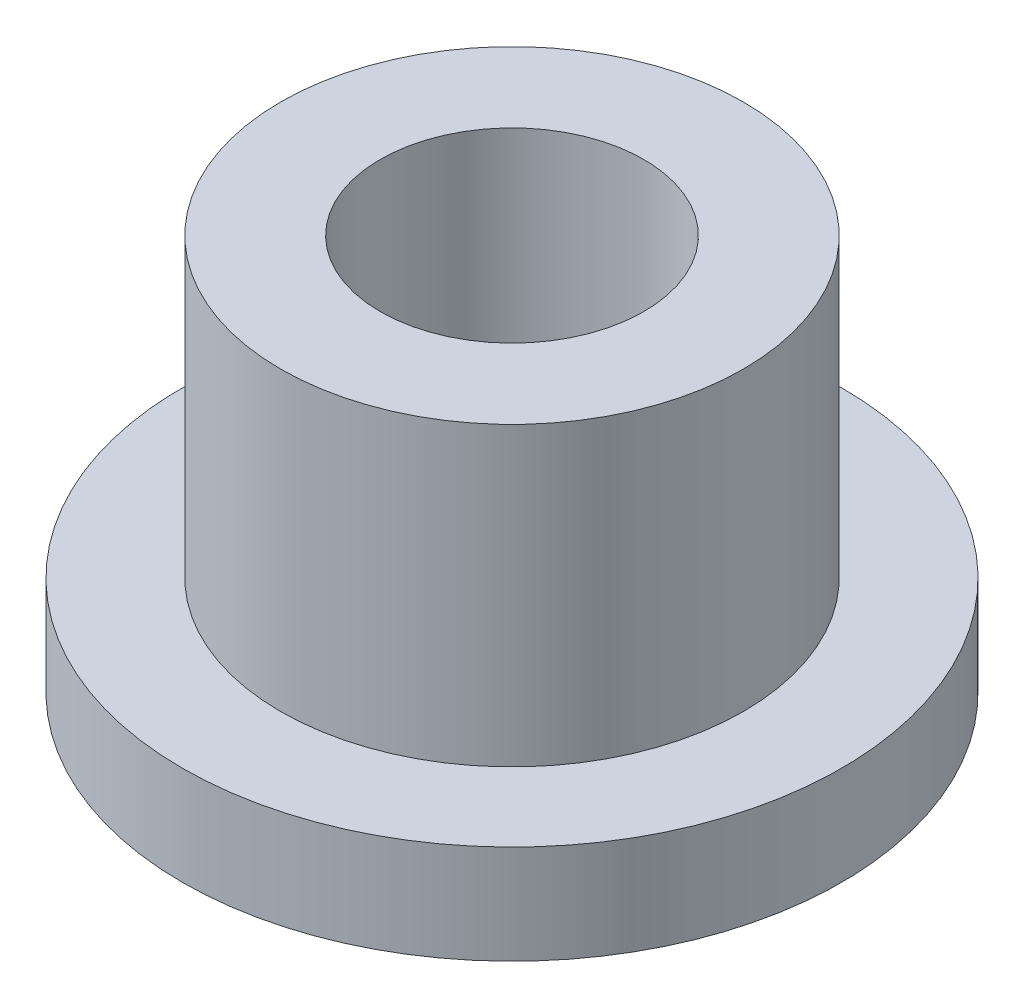
from build123d import *

# Parameters (mm, degrees)
SKETCH2_R           = 3.51
SKETCH2_R_2         = 2
BOSS_EXTRUDE1_DEPTH = 6
SKETCH3_R           = 5
SKETCH3_R_2         = 3.51
BOSS_EXTRUDE2_DEPTH = 1.5


with BuildPart() as part:
    # Sketch2 → Boss-Extrude1 (new body)
    with BuildSketch(Plane(origin=(0, 0, 0), x_dir=(1, 0, 0), z_dir=(0, 1, 0))):
        Circle(SKETCH2_R)
        Circle(SKETCH2_R_2, mode=Mode.SUBTRACT)
    extrude(amount=BOSS_EXTRUDE1_DEPTH)

    # Sketch3 → Boss-Extrude2 (add)
    with BuildSketch(Plane(origin=(0, 0, 0), x_dir=(1, 0, 0), z_dir=(0, 1, 0))):
        Circle(SKETCH3_R)
        Circle(SKETCH3_R_2, mode=Mode.SUBTRACT)
    extrude(amount=BOSS_EXTRUDE2_DEPTH)


solid = part.part
